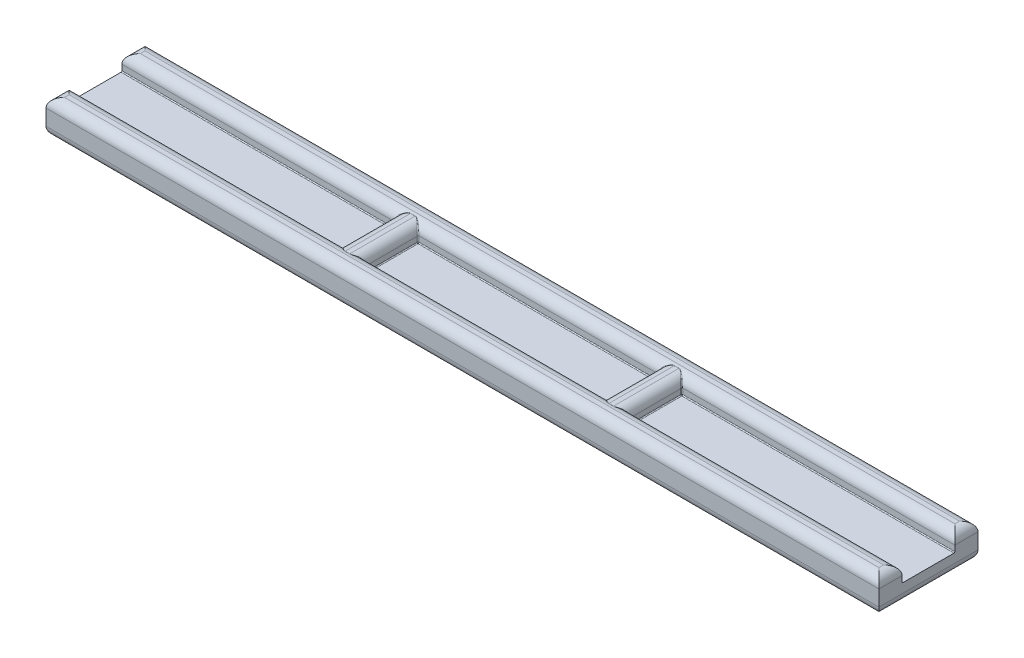
from build123d import *

# Parameters (mm, degrees)
BOSS_EXTRUDE1_DEPTH  = 90
FILLET1_R            = 1
FILLET2_R            = 0.1
BOSS_EXTRUDE2_START  = -3.53775
SKETCH2_W            = 2.5
SKETCH2_H            = 1.65
BOSS_EXTRUDE2_DEPTH  = 7.0755
FILLET4_R            = 1
FILLET5_R            = 0.1
FILLET4_OF_MIRROR1_R = 1
FILLET5_OF_MIRROR1_R = 0.1


with BuildPart() as part:
    # Sketch1 → Boss-Extrude1 (new body)
    with BuildSketch(Plane(origin=(0, 0, 0), x_dir=(0, 0, -1), z_dir=(1, 0, 0))):
        Polygon((-5.35, 0), (5.35, 0), (5.35, 3.7), (2.85, 3.7), (2.85, 2), (-2.85, 2), (-2.85, 3.7), (-5.35, 3.7), align=None)
    extrude(amount=BOSS_EXTRUDE1_DEPTH)

    # Fillet1
    fillet1_edges = [part.edges().sort_by_distance(p)[0] for p in [
        (0, 3.7, 4.1),
        (45, 3.7, -2.85),
        (45, 3.7, -5.35),
        (45, 0, -5.35),
        (45, 0, 5.35),
        (45, 3.7, 5.35),
        (45, 3.7, 2.85),
        (90, 3.7, 4.1),
        (90, 0, 0),
        (90, 3.7, -4.1),
        (0, 3.7, -4.1),
        (0, 0, 0),
    ]]
    fillet(fillet1_edges, radius=FILLET1_R)

    # Fillet2
    fillet2_edges = [part.edges().sort_by_distance(p)[0] for p in [
        (45, 2, 2.85),
        (45, 2, -2.85),
    ]]
    fillet(fillet2_edges, radius=FILLET2_R)

    # Sketch2 → Boss-Extrude2 (add)
    with BuildSketch(Plane.XY.offset(BOSS_EXTRUDE2_START)):
        with Locations((30.75, 2.825)):
            Rectangle(SKETCH2_W, SKETCH2_H)
    boss_extrude2 = extrude(amount=BOSS_EXTRUDE2_DEPTH)

    # Fillet4
    fillet4_edges = [part.edges().sort_by_distance(p)[0] for p in [
        (32, 3.65, 0),
        (29.5, 3.65, 0),
    ]]
    fillet(fillet4_edges, radius=FILLET4_R)

    # Fillet5
    fillet5_edges = [part.edges().sort_by_distance(p)[0] for p in [
        (32, 2.375, -2.85),
        (30.75, 3.65, -3.53775),
        (30.75, 3.65, 3.53775),
        (29.5, 2.375, 2.85),
        (31.999687256, 2.675007821, 2.85),
        (31.668606453, 3.393616444, 3.129655481),
        (31.668606453, 3.393616444, -3.129655483),
        (31.999687256, 2.675007821, -2.85),
        (29.831393547, 3.393616444, 3.129655481),
        (29.500312744, 2.675007821, 2.85),
        (29.500312744, 2.675007821, -2.85),
        (29.831393547, 3.393616444, -3.129655483),
        (29.5, 2.029289322, 2.820710678),
        (32, 2.029289322, 2.820710678),
        (32, 2.029289322, -2.820710678),
        (32, 2, 0),
        (29.5, 2, 0),
        (29.5, 2.029289322, -2.820710678),
        (29.5, 2.375, -2.85),
        (32, 2.375, 2.85),
    ]]
    fillet(fillet5_edges, radius=FILLET5_R)

    # Mirror1: Boss-Extrude2 across plane
    add(boss_extrude2.mirror(Plane(origin=(45, 0, 0), x_dir=(0, 0, 1), z_dir=(1, 0, 0))))

    # Fillet4 of Mirror1
    fillet4_of_mirror1_edges = [part.edges().sort_by_distance(p)[0] for p in [
        (58, 3.65, 0),
        (60.5, 3.65, 0),
    ]]
    fillet(fillet4_of_mirror1_edges, radius=FILLET4_OF_MIRROR1_R)

    # Fillet5 of Mirror1
    fillet5_of_mirror1_edges = [part.edges().sort_by_distance(p)[0] for p in [
        (58, 2.375, -2.85),
        (59.25, 3.65, -3.53775),
        (59.25, 3.65, 3.53775),
        (60.5, 2.375, 2.85),
        (58.000312744, 2.675007821, 2.85),
        (58.331393547, 3.393616444, 3.129655481),
        (58.331393547, 3.393616444, -3.129655483),
        (58.000312744, 2.675007821, -2.85),
        (60.168606453, 3.393616444, 3.129655481),
        (60.499687256, 2.675007821, 2.85),
        (60.499687256, 2.675007821, -2.85),
        (60.168606453, 3.393616444, -3.129655483),
        (60.5, 2.029289322, 2.820710678),
        (58, 2.029289322, 2.820710678),
        (58, 2.029289322, -2.820710678),
        (58, 2, 0),
        (60.5, 2, 0),
        (60.5, 2.029289322, -2.820710678),
        (60.5, 2.375, -2.85),
        (58, 2.375, 2.85),
    ]]
    fillet(fillet5_of_mirror1_edges, radius=FILLET5_OF_MIRROR1_R)


solid = part.part
